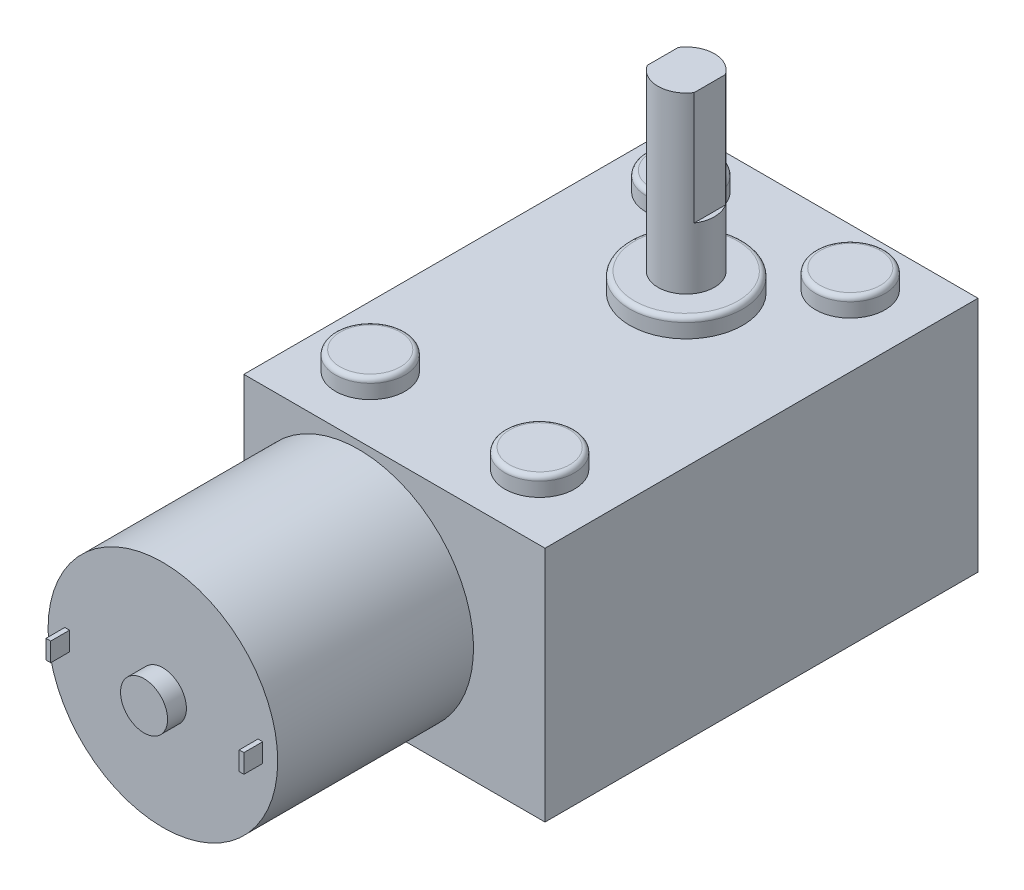
from build123d import *

# Parameters (mm, degrees)
CROQUIS1_W              = 32
CROQUIS1_H              = 46
CROQUIS1_R              = 6
CROQUIS1_R_2            = 3.7
SALIENTE_EXTRUIR1_DEPTH = 25.2
CROQUIS2_R              = 3.7
CROQUIS2_R_2            = 6
SALIENTE_EXTRUIR2_DEPTH = 2
CROQUIS3_R              = 12.2
SALIENTE_EXTRUIR3_DEPTH = 20.8
CROQUIS4_R              = 2.5
SALIENTE_EXTRUIR4_DEPTH = 2
CROQUIS5_W              = 0.5
CROQUIS5_H              = 2
SALIENTE_EXTRUIR5_DEPTH = 2
CROQUIS6_R              = 3
SALIENTE_EXTRUIR6_DEPTH = 18.5
CORTAR_EXTRUIR1_DEPTH   = 12
REDONDEO2_R             = 0.5


with BuildPart() as part:
    # Croquis1 → Saliente-Extruir1 (new body)
    with BuildSketch(Plane(origin=(0, 0, 0), x_dir=(1, 0, 0), z_dir=(0, 1, 0))):
        Rectangle(CROQUIS1_W, CROQUIS1_H)
        with Locations((0, 8)):
            Circle(CROQUIS1_R, mode=Mode.SUBTRACT)
        with Locations((8.430868167, -16)):
            Circle(CROQUIS1_R_2, mode=Mode.SUBTRACT)
        with Locations((-9.569131833, -16)):
            Circle(CROQUIS1_R_2, mode=Mode.SUBTRACT)
        with Locations((8.430868167, 17)):
            Circle(CROQUIS1_R_2, mode=Mode.SUBTRACT)
        with Locations((-9.569131833, 17)):
            Circle(CROQUIS1_R_2, mode=Mode.SUBTRACT)
        with Locations((0, 8)):
            Circle(CROQUIS1_R)
        with Locations((-9.569131833, 17)):
            Circle(CROQUIS1_R_2)
        with Locations((8.430868167, 17)):
            Circle(CROQUIS1_R_2)
        with Locations((-9.569131833, -16)):
            Circle(CROQUIS1_R_2)
        with Locations((8.430868167, -16)):
            Circle(CROQUIS1_R_2)
    extrude(amount=SALIENTE_EXTRUIR1_DEPTH)

    # Croquis2 → Saliente-Extruir2 (add)
    with BuildSketch(Plane(origin=(0, 25.2, 0), x_dir=(1, 0, 0), z_dir=(0, 1, 0))):
        with Locations((-9.569131833, 17)):
            Circle(CROQUIS2_R)
        with Locations((8.430868167, 17)):
            Circle(CROQUIS2_R)
        with Locations((8.430868167, -16)):
            Circle(CROQUIS2_R)
        with Locations((-9.569131833, -16)):
            Circle(CROQUIS2_R)
        with Locations((0, 8)):
            Circle(CROQUIS2_R_2)
    extrude(amount=SALIENTE_EXTRUIR2_DEPTH)

    # Croquis3 → Saliente-Extruir3 (add)
    with BuildSketch(Plane.XY.offset(23)):
        with Locations((-3.8, 12.2)):
            Circle(CROQUIS3_R)
    extrude(amount=SALIENTE_EXTRUIR3_DEPTH)

    # Croquis4 → Saliente-Extruir4 (add)
    with BuildSketch(Plane.XY.offset(43.8)):
        with Locations((-3.8, 12.2)):
            Circle(CROQUIS4_R)
    extrude(amount=SALIENTE_EXTRUIR4_DEPTH)

    # Croquis5 → Saliente-Extruir5 (add)
    with BuildSketch(Plane.XY.offset(43.8)):
        with Locations((6.559315441, 12.2)):
            Rectangle(CROQUIS5_W, CROQUIS5_H)
        with Locations((-13.968008184, 12.2)):
            Rectangle(CROQUIS5_W, CROQUIS5_H)
    extrude(amount=SALIENTE_EXTRUIR5_DEPTH)

    # Croquis6 → Saliente-Extruir6 (add)
    with BuildSketch(Plane(origin=(0, 27.2, 0), x_dir=(1, 0, 0), z_dir=(0, 1, 0))):
        with Locations((0, 8)):
            Circle(CROQUIS6_R)
    extrude(amount=SALIENTE_EXTRUIR6_DEPTH)

    # Croquis7 → Cortar-Extruir1 (cut)
    with BuildSketch(Plane(origin=(0, 45.7, 0), x_dir=(1, 0, 0), z_dir=(0, 1, 0))):
        with BuildLine():
            Line((-2.5, 6.341687605), (-2.5, 9.658312395))
            ThreePointArc((-2.5, 9.658312395), (-3, 8), (-2.5, 6.341687605))
        make_face()
        with BuildLine():
            Line((2.5, 6.341687605), (2.5, 9.658312395))
            ThreePointArc((2.5, 9.658312395), (3, 8), (2.5, 6.341687605))
        make_face()
    extrude(amount=-CORTAR_EXTRUIR1_DEPTH, mode=Mode.SUBTRACT)

    # Redondeo2
    redondeo2_edges = [part.edges().sort_by_distance(p)[0] for p in [
        (-13.269131833, 27.2, -17),
        (4.730868167, 27.2, -17),
        (4.730868167, 27.2, 16),
        (-13.269131833, 27.2, 16),
        (-6, 27.2, -8),
    ]]
    fillet(redondeo2_edges, radius=REDONDEO2_R)


solid = part.part
